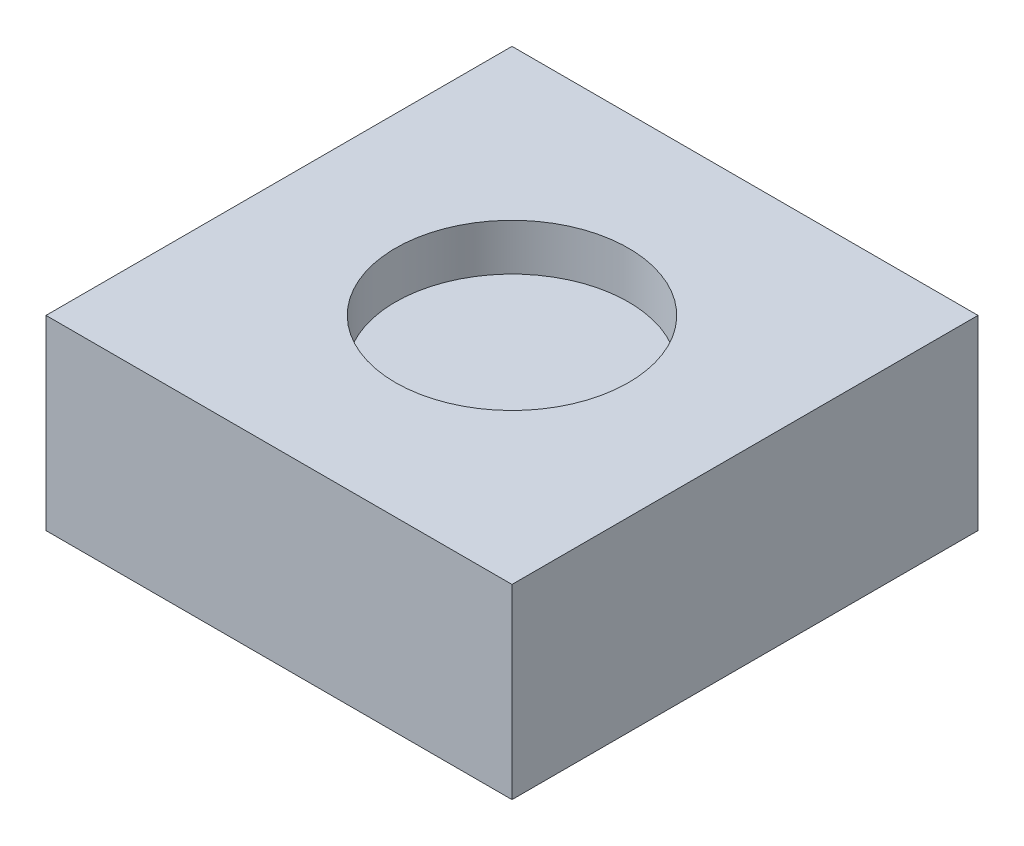
from build123d import *

# Parameters (mm, degrees)
SKETCH1_W           = 20
SKETCH1_H           = 20
BOSS_EXTRUDE1_DEPTH = 8
SKETCH2_R           = 5
CUT_EXTRUDE1_DEPTH  = 2
SKETCH3_R           = 1
CUT_EXTRUDE2_DEPTH  = 2
FILLET1_R           = 1


with BuildPart() as part:
    # Sketch1 → Boss-Extrude1 (new body)
    with BuildSketch(Plane(origin=(0, 0, 0), x_dir=(1, 0, 0), z_dir=(0, 1, 0))):
        Rectangle(SKETCH1_W, SKETCH1_H)
    extrude(amount=BOSS_EXTRUDE1_DEPTH)

    # Sketch2 → Cut-Extrude1 (cut)
    with BuildSketch(Plane(origin=(0, 8, 0), x_dir=(1, 0, 0), z_dir=(0, 1, 0))):
        Circle(SKETCH2_R)
    extrude(amount=-CUT_EXTRUDE1_DEPTH, mode=Mode.SUBTRACT)

    # Sketch3 → Cut-Extrude2 (cut)
    with BuildSketch(Plane.XZ):
        Circle(SKETCH3_R)
    extrude(amount=-CUT_EXTRUDE2_DEPTH, mode=Mode.SUBTRACT)

    # Fillet1
    fillet1_edges = [part.edges().sort_by_distance(p)[0] for p in [
        (-1, 2, 0),
    ]]
    fillet(fillet1_edges, radius=FILLET1_R)


solid = part.part
